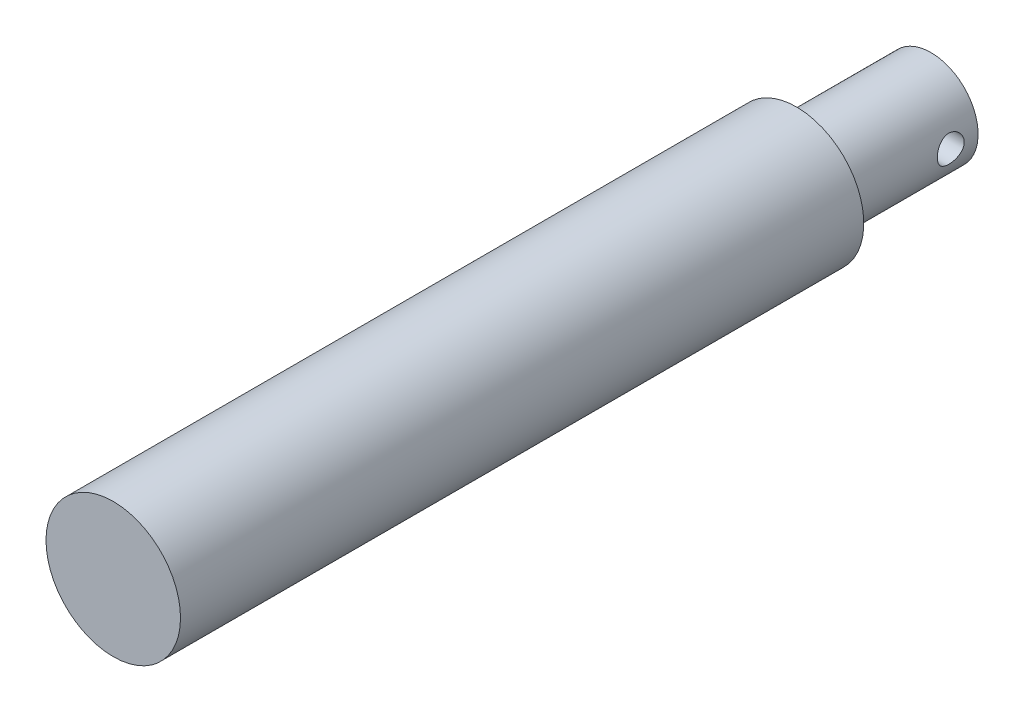
from build123d import *

# Parameters (mm, degrees)
SKETCH1_R               = 5
BOSS_EXTRUDE1_DEPTH     = 60.8
SKETCH2_R               = 1
CUT_EXTRUDE1_DEPTH      = 6
CUT_EXTRUDE1_DEPTH_BACK = 6
SKETCH3_OUTSIDE_W       = 24.484
SKETCH3_OUTSIDE_H       = 24.484
SKETCH3_OUTSIDE_R       = 3.5
CUT_EXTRUDE2_DEPTH      = 10


with BuildPart() as part:
    # Sketch1 → Boss-Extrude1 (new body)
    with BuildSketch(Plane.XY):
        Circle(SKETCH1_R)
    extrude(amount=BOSS_EXTRUDE1_DEPTH)

    # Sketch2 → Cut-Extrude1 (cut, two sides)
    with BuildSketch(Plane(origin=(0, 0, 0), x_dir=(0, 0, -1), z_dir=(1, 0, 0))) as cut_extrude1_sk:
        with Locations((-2.031417136, 0)):
            Circle(SKETCH2_R)
    extrude(amount=CUT_EXTRUDE1_DEPTH, mode=Mode.SUBTRACT)
    extrude(cut_extrude1_sk.sketch, amount=-CUT_EXTRUDE1_DEPTH_BACK, mode=Mode.SUBTRACT)

    # Sketch3 outside → Cut-Extrude2 (cut)
    with BuildSketch(Plane(origin=(0, 0, 0), x_dir=(-1, 0, 0), z_dir=(0, 0, -1))):
        Rectangle(SKETCH3_OUTSIDE_W, SKETCH3_OUTSIDE_H)
        Circle(SKETCH3_OUTSIDE_R, mode=Mode.SUBTRACT)
    extrude(amount=-CUT_EXTRUDE2_DEPTH, mode=Mode.SUBTRACT)


solid = part.part
